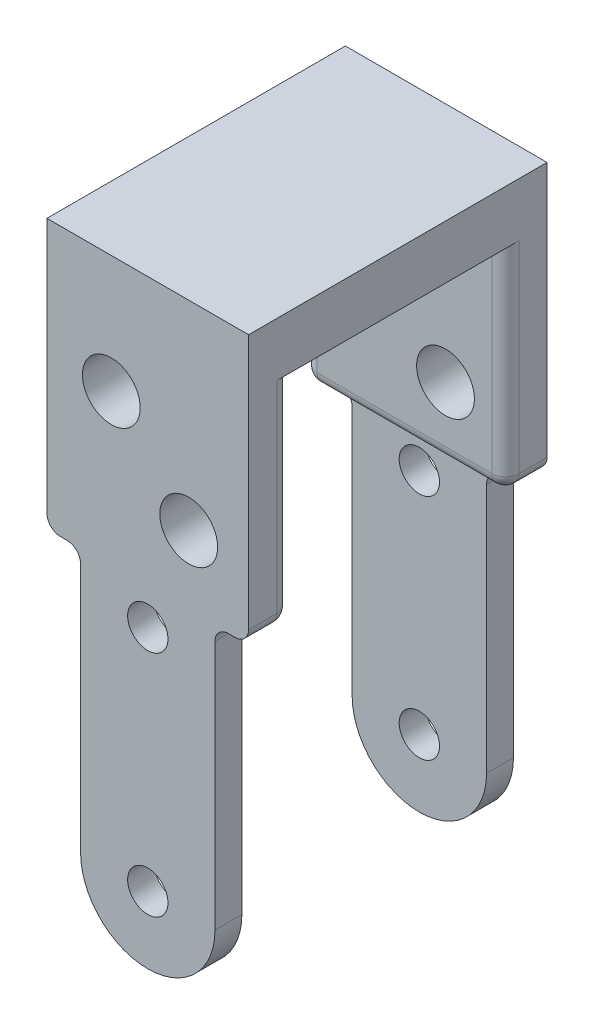
from build123d import *

# Parameters (mm, degrees)
BOSS_EXTRUDE1_START   = 0.1
SKETCH1_R             = 1.5
BOSS_EXTRUDE1_DEPTH   = 2
SKETCH2_W             = 15
SKETCH2_H             = 3.1
SKETCH2_W_2           = 10
SKETCH2_H_2           = 2
BOSS_EXTRUDE2_DEPTH   = 16
SKETCH3_W             = 15
SKETCH3_H             = 22.2
BOSS_EXTRUDE3_DEPTH   = 4
BOSS_EXTRUDE4_START   = -20.1
SKETCH1_3_R           = 1.5
BOSS_EXTRUDE4_DEPTH   = 2
FILLET1_R             = 1
FILLET2_R             = 1
F_4_0MM_DOWEL_HOLE1_D = 4.3


with BuildPart() as part:
    # Sketch1 → Boss-Extrude1 (new body)
    with BuildSketch(Plane.XY.offset(BOSS_EXTRUDE1_START)):
        with BuildLine():
            Line((-8.650697236, -36.32930415), (-8.650697236, -16.72930415))
            Line((-8.650697236, -16.72930415), (1.349302764, -16.72930415))
            Line((1.349302764, -16.72930415), (1.349302764, -36.32930415))
            ThreePointArc((1.349302764, -36.32930415), (-3.650697236, -41.32930415), (-8.650697236, -36.32930415))
        make_face()
        with Locations((-3.650697236, -19.32930415)):
            Circle(SKETCH1_R, mode=Mode.SUBTRACT)
        with Locations((-3.650697236, -36.32930415)):
            Circle(SKETCH1_R, mode=Mode.SUBTRACT)
    extrude(amount=BOSS_EXTRUDE1_DEPTH)

    # Sketch2 → Boss-Extrude2 (add)
    with BuildSketch(Plane(origin=(0, -16.72930415, 0), x_dir=(1, 0, 0), z_dir=(0, 1, 0))):
        with Locations((-3.650697236, 18.55)):
            Rectangle(SKETCH2_W, SKETCH2_H)
        Polygon((3.849302764, 1), (-11.150697236, 1), (-11.150697236, -2.1), (-8.650697236, -2.1), (-8.650697236, -0.1), (1.349302764, -0.1), (1.349302764, -2.1), (3.849302764, -2.1), align=None)
        with Locations((-3.650697236, -1.1)):
            Rectangle(SKETCH2_W_2, SKETCH2_H_2)
    extrude(amount=BOSS_EXTRUDE2_DEPTH)

    # Sketch3 → Boss-Extrude3 (add)
    with BuildSketch(Plane(origin=(0, -0.72930415, 0), x_dir=(1, 0, 0), z_dir=(0, 1, 0))):
        with Locations((-3.650697236, 9)):
            Rectangle(SKETCH3_W, SKETCH3_H)
    extrude(amount=BOSS_EXTRUDE3_DEPTH)

    # Sketch1_3 → Boss-Extrude4 (add)
    with BuildSketch(Plane.XY.offset(BOSS_EXTRUDE4_START)):
        with BuildLine():
            Line((-8.650697236, -36.32930415), (-8.650697236, -16.72930415))
            Line((-8.650697236, -16.72930415), (1.349302764, -16.72930415))
            Line((1.349302764, -16.72930415), (1.349302764, -36.32930415))
            ThreePointArc((1.349302764, -36.32930415), (-3.650697236, -41.32930415), (-8.650697236, -36.32930415))
        make_face()
        with Locations((-3.650697236, -19.32930415)):
            Circle(SKETCH1_3_R, mode=Mode.SUBTRACT)
        with Locations((-3.650697236, -36.32930415)):
            Circle(SKETCH1_3_R, mode=Mode.SUBTRACT)
    extrude(amount=BOSS_EXTRUDE4_DEPTH)

    # Fillet1
    fillet1_edges = [part.edges().sort_by_distance(p)[0] for p in [
        (3.849302764, -16.72930415, 0.55),
        (-11.150697236, -16.72930415, 0.55),
        (3.849302764, -16.72930415, -18.55),
        (-11.150697236, -16.72930415, -18.55),
        (-8.650697236, -16.72930415, -19.1),
        (1.349302764, -16.72930415, -19.1),
        (-8.650697236, -16.72930415, 1.1),
        (1.349302764, -16.72930415, 1.1),
    ]]
    fillet(fillet1_edges, radius=FILLET1_R)

    # Fillet2
    fillet2_edges = [part.edges().sort_by_distance(p)[0] for p in [
        (-11.150697236, -8.22930415, -1),
        (3.849302764, -8.22930415, -1),
        (-11.150697236, -8.22930415, -17),
        (3.849302764, -8.22930415, -17),
        (-3.650697236, -16.72930415, -17),
        (-10.857804017, -16.436410931, -17),
        (3.556409546, -16.436410931, -17),
        (-3.650697236, -16.72930415, -1),
        (3.556409546, -16.436410931, -1),
        (-10.857804017, -16.436410931, -1),
    ]]
    fillet(fillet2_edges, radius=FILLET2_R)

    # Ø4.0mm Dowel Hole1 (through all)
    with Locations(Plane(origin=(-6.364117909, -5.47483866, -20.1), x_dir=(-1, 0, 0), z_dir=(0, 0, -1))):
        with Locations((0, 0), (-5.759484696, -6.093076476)):
            Hole(F_4_0MM_DOWEL_HOLE1_D / 2)


solid = part.part
